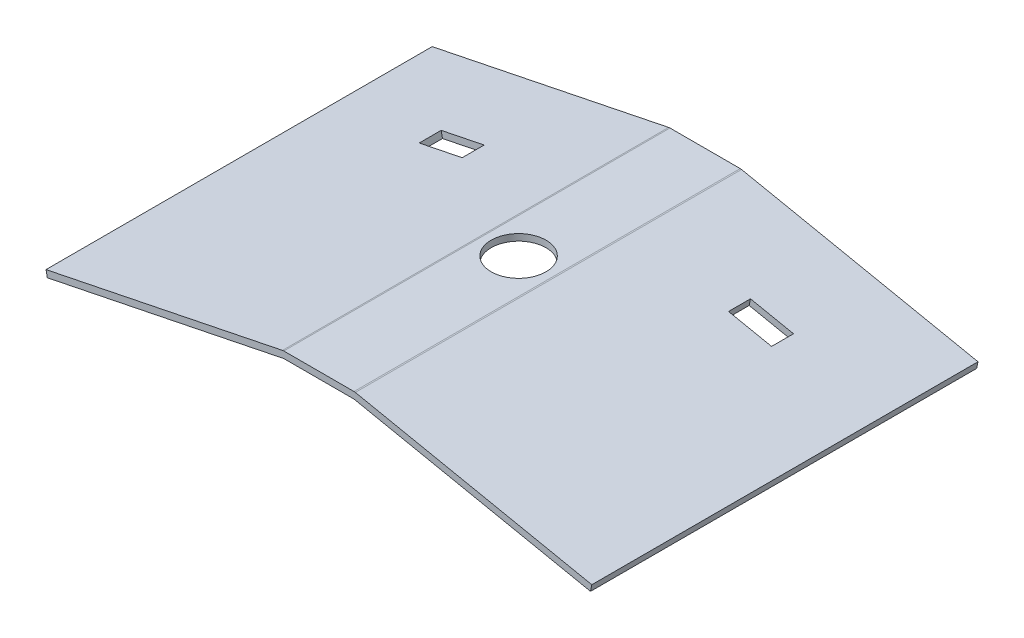
from build123d import *

# Parameters (mm, degrees)
BOSS_EXTRUDE1_DEPTH      = 3
BOSS_EXTRUDE2_DEPTH      = 88
BOSS_EXTRUDE2_DEPTH_BACK = 88
CUT_EXTRUDE1_DEPTH       = 50
SKETCH4_R                = 12.5
CUT_EXTRUDE2_DEPTH       = 25.999792682
SKETCH5_W                = 20
SKETCH5_H                = 10
CUT_EXTRUDE3_DEPTH       = 53.630567568
SKETCH6_W                = 20
SKETCH6_H                = 10
CUT_EXTRUDE4_DEPTH       = 53.630567568


with BuildPart() as part:
    # Sketch1 → Boss-Extrude1 (new body)
    with BuildSketch(Plane.XY):
        Polygon((-16, 19.999811529), (16, 19.999811529), (113.979628183, 0), (113.979628183, -10), (-113.979628183, -10), (-113.979628183, 0), align=None)
    extrude(amount=BOSS_EXTRUDE1_DEPTH)

    # Sketch2 → Boss-Extrude2 (add, two sides)
    with BuildSketch(Plane.XY.offset(3)) as boss_extrude2_sk:
        Polygon((-113.979628183, 0), (-16, 19.999811529), (16, 19.999811529), (113.979628183, 0), (123.777591001, -1.999981153), (124.377585347, 0.939407693), (16.599994346, 22.939200374), (16, 22.999811529), (-16, 22.999811529), (-16.599994346, 22.939200374), (-124.377585347, 0.939407693), (-123.777591001, -1.999981153), align=None)
    extrude(amount=BOSS_EXTRUDE2_DEPTH)
    extrude(boss_extrude2_sk.sketch, amount=-BOSS_EXTRUDE2_DEPTH_BACK)

    # Sketch3 → Cut-Extrude1 (cut)
    with BuildSketch(Plane.XY.offset(3)):
        Polygon((113.979628183, 0), (16, 19.999811529), (-16, 19.999811529), (-113.979628183, 0), (-113.979628183, -10), (113.979628183, -10), align=None)
    extrude(amount=-CUT_EXTRUDE1_DEPTH, mode=Mode.SUBTRACT)

    # Sketch4 → Cut-Extrude2 (cut, through all)
    with BuildSketch(Plane(origin=(0, 22.999811529, 0), x_dir=(1, 0, 0), z_dir=(0, 1, 0))):
        Circle(SKETCH4_R)
    extrude(amount=-CUT_EXTRUDE2_DEPTH, mode=Mode.SUBTRACT)

    # Sketch5 → Cut-Extrude3 (cut, through all)
    with BuildSketch(Plane(origin=(-5.159093546, 25.274541546, 0), x_dir=(0.979796282, 0.199998115, 0), z_dir=(-0.199998115, 0.979796282, 0))):
        with Locations((-66.676815897, 40)):
            Rectangle(SKETCH5_W, SKETCH5_H)
    extrude(amount=-CUT_EXTRUDE3_DEPTH, mode=Mode.SUBTRACT)

    # Sketch6 → Cut-Extrude4 (cut, through all)
    with BuildSketch(Plane(origin=(5.159093546, 25.274541546, 0), x_dir=(0.979796282, -0.199998115, 0), z_dir=(0.199998115, 0.979796282, 0))):
        with Locations((66.676815897, 40)):
            Rectangle(SKETCH6_W, SKETCH6_H)
    extrude(amount=-CUT_EXTRUDE4_DEPTH, mode=Mode.SUBTRACT)


solid = part.part
